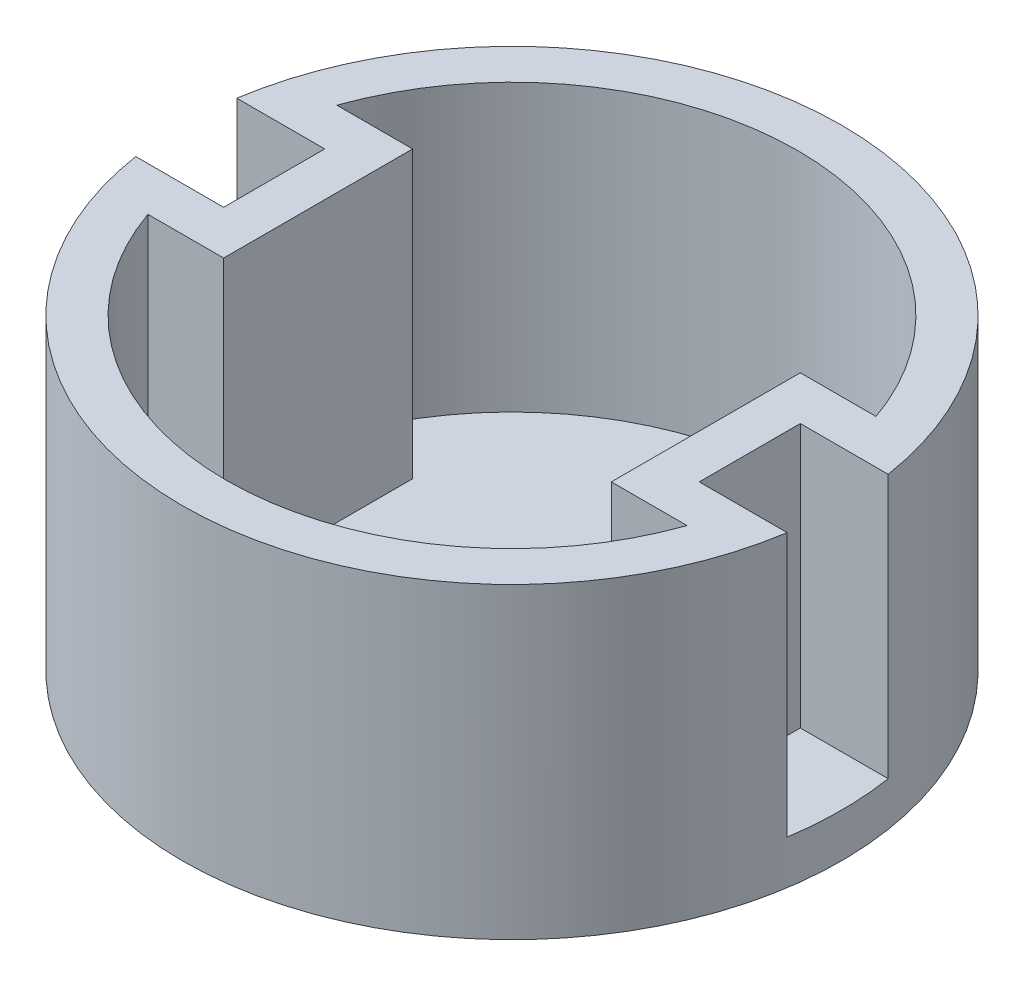
from build123d import *

# Parameters (mm, degrees)
SKETCH1_R           = 75
BOSS_EXTRUDE1_DEPTH = 70
CUT_EXTRUDE1_DEPTH  = 65
SKETCH3_3_W         = 21.992128126
SKETCH3_3_H         = 23
SKETCH3_3_W_2       = 22.893011501
CUT_EXTRUDE3_DEPTH  = 60
BOSS_EXTRUDE2_START = 65
BOSS_EXTRUDE2_DEPTH = 65


with BuildPart() as part:
    # Sketch1 → Boss-Extrude1 (new body)
    with BuildSketch(Plane(origin=(0, 0, 0), x_dir=(1, 0, 0), z_dir=(0, 1, 0))):
        with Locations((-19.143760263, 2.851198337)):
            Circle(SKETCH1_R)
    extrude(amount=BOSS_EXTRUDE1_DEPTH)

    # Sketch3 → Cut-Extrude1 (cut)
    with BuildSketch(Plane(origin=(0, 70, 0), x_dir=(1, 0, 0), z_dir=(0, 1, 0))):
        with BuildLine():
            Line((34.969329, 14.351198337), (44.830844074, 14.351198337))
            ThreePointArc((44.830844074, 14.351198337), (-19.143760263, 67.851198337), (-83.118364599, 14.351198337))
            Line((-83.118364599, 14.351198337), (-73.256849525, 14.351198337))
            Line((-73.256849525, 14.351198337), (-73.256849525, -8.648801663))
            Line((-73.256849525, -8.648801663), (-83.118364599, -8.648801663))
            ThreePointArc((-83.118364599, -8.648801663), (-19.143760263, -62.148801663), (44.830844074, -8.648801663))
            Line((44.830844074, -8.648801663), (34.969329, -8.648801663))
            Line((34.969329, -8.648801663), (34.969329, 14.351198337))
        make_face()
    extrude(amount=-CUT_EXTRUDE1_DEPTH, mode=Mode.SUBTRACT)

    # Sketch3_3 → Cut-Extrude3 (cut)
    with BuildSketch(Plane(origin=(0, 70, 0), x_dir=(1, 0, 0), z_dir=(0, 1, 0))):
        with Locations((45.965393063, 2.851198337)):
            Rectangle(SKETCH3_3_W, SKETCH3_3_H)
        with Locations((-84.703355276, 2.851198337)):
            Rectangle(SKETCH3_3_W_2, SKETCH3_3_H)
    extrude(amount=-CUT_EXTRUDE3_DEPTH, mode=Mode.SUBTRACT)

    # Sketch6 → Boss-Extrude2 (add)
    with BuildSketch(Plane(origin=(0, 5, 0), x_dir=(1, 0, 0), z_dir=(0, 1, 0)).offset(BOSS_EXTRUDE2_START)):
        with BuildLine():
            ThreePointArc((-80.485018809, 24.351198337), (-82.000871018, 19.403649138), (-83.118364599, 14.351198337))
            Line((-83.118364599, 14.351198337), (-73.256849525, 14.351198337))
            Line((-73.256849525, 14.351198337), (-73.256849525, -8.648801663))
            Line((-73.256849525, -8.648801663), (-83.118364599, -8.648801663))
            ThreePointArc((-83.118364599, -8.648801663), (-82.000871018, -13.701252464), (-80.485018809, -18.648801663))
            Line((-80.485018809, -18.648801663), (-63.256849525, -18.648801663))
            Line((-63.256849525, -18.648801663), (-63.256849525, 24.351198337))
            Line((-63.256849525, 24.351198337), (-80.485018809, 24.351198337))
        make_face()
        with BuildLine():
            ThreePointArc((44.830844074, 14.351198337), (43.713350492, 19.403649138), (42.197498283, 24.351198337))
            Line((42.197498283, 24.351198337), (24.969329, 24.351198337))
            Line((24.969329, 24.351198337), (24.969329, -18.648801663))
            Line((24.969329, -18.648801663), (42.197498283, -18.648801663))
            ThreePointArc((42.197498283, -18.648801663), (43.713350492, -13.701252464), (44.830844074, -8.648801663))
            Line((44.830844074, -8.648801663), (34.969329, -8.648801663))
            Line((34.969329, -8.648801663), (34.969329, 14.351198337))
            Line((34.969329, 14.351198337), (44.830844074, 14.351198337))
        make_face()
    extrude(amount=-BOSS_EXTRUDE2_DEPTH)


solid = part.part
